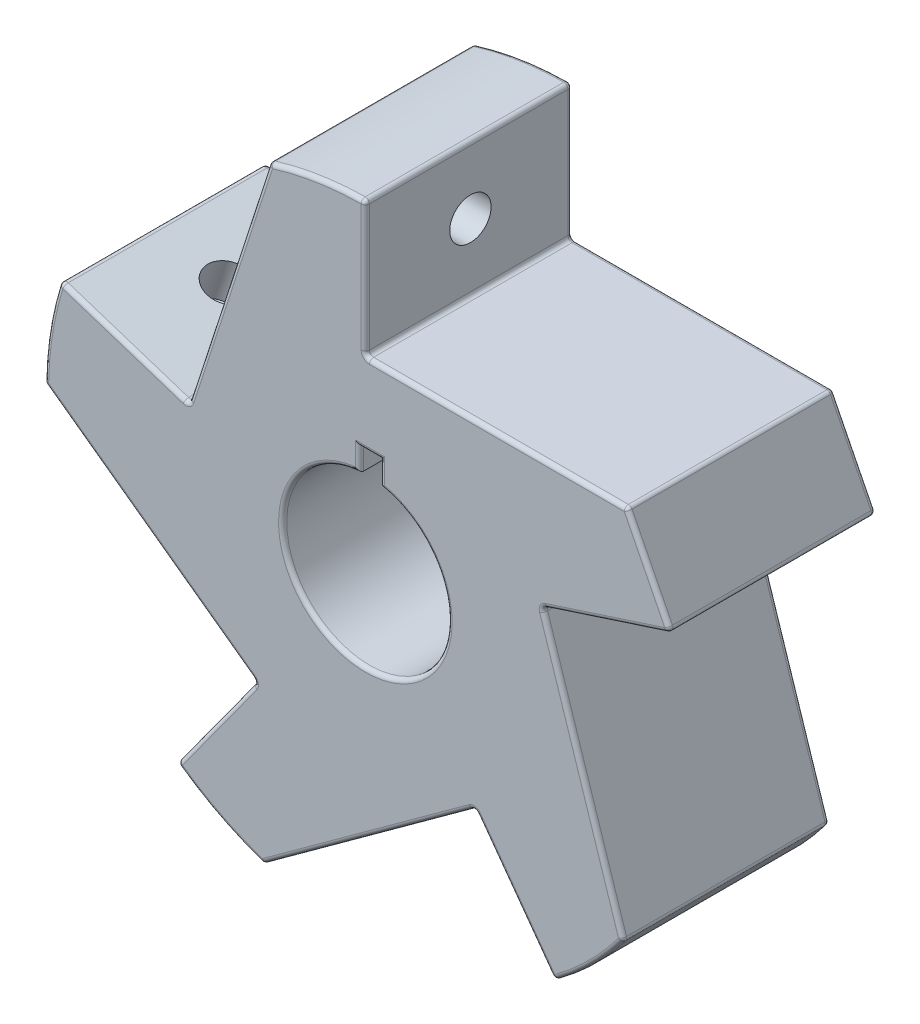
from build123d import *

# Parameters (mm, degrees)
SKETCH1_R           = 20
BOSS_EXTRUDE2_DEPTH = 50
SKETCH2_W           = 5
SKETCH2_H           = 11
CUT_EXTRUDE3_DEPTH  = 60
FILLET1_R           = 1
SKETCH3_R           = 5.003643642
CUT_EXTRUDE4_DEPTH  = 10
SKETCH4_R           = 5
CUT_EXTRUDE5_DEPTH  = 10
SKETCH5_R           = 5
CUT_EXTRUDE6_DEPTH  = 10
SKETCH6_R           = 5
CUT_EXTRUDE7_DEPTH  = 10
SKETCH7_R           = 5
CUT_EXTRUDE8_DEPTH  = 10


with BuildPart() as part:
    # Sketch1 → Boss-Extrude2 (new body)
    with BuildSketch(Plane.XY):
        with BuildLine():
            Line((-23.253592475, 74.055860248), (-42.797543233, 13.905764747))
            Line((-42.797543233, 13.905764747), (-73.821837525, 23.986169024))
            ThreePointArc((-73.821837525, 23.986169024), (-76.604138186, 12.522220762), (-77.617063713, 0.769038699))
            Line((-77.617063713, 0.769038699), (-26.450336353, -36.405764747))
            Line((-26.450336353, -36.405764747), (-45.624404702, -62.796605765))
            ThreePointArc((-45.624404702, -62.796605765), (-35.581320193, -68.985285774), (-24.716391007, -73.580568193))
            Line((-24.716391007, -73.580568193), (26.450336353, -36.405764747))
            Line((26.450336353, -36.405764747), (45.624404702, -62.796605765))
            ThreePointArc((45.624404702, -62.796605765), (54.613672942, -55.157472094), (62.341493992, -46.244330754))
            Line((62.341493992, -46.244330754), (42.797543233, 13.905764747))
            Line((42.797543233, 13.905764747), (73.821837525, 23.986169024))
            Line((73.821837525, 23.986169024), (63.245553203, 45))
            Line((63.245553203, 45), (0, 45))
            Line((0, 45), (0, 77.620873481))
            ThreePointArc((0, 77.620873481), (-11.762640885, 76.72444382), (-23.253592475, 74.055860248))
        make_face()
        Circle(SKETCH1_R, mode=Mode.SUBTRACT)
    extrude(amount=BOSS_EXTRUDE2_DEPTH)

    # Sketch2 → Cut-Extrude3 (cut)
    with BuildSketch(Plane.XY):
        with Locations((1.091953982, 19.974403848)):
            Rectangle(SKETCH2_W, SKETCH2_H)
    extrude(amount=CUT_EXTRUDE3_DEPTH, mode=Mode.SUBTRACT)

    # Fillet1
    fillet1_edges = [part.edges().sort_by_distance(p)[0] for p in [
        (-11.762640885, 76.72444382, 50),
        (-33.025567854, 43.980812497, 50),
        (31.622776602, 45, 0),
        (68.533695364, 34.493084512, 0),
        (58.309690379, 18.945966885, 0),
        (52.569518613, -16.169283004, 0),
        (54.613672942, -55.157472094, 0),
        (36.037370528, -49.601185256, 0),
        (-58.309690379, 18.945966885, 50),
        (0.866972673, -54.99316647, 0),
        (-35.581320193, -68.985285774, 0),
        (-36.037370528, -49.601185256, 0),
        (-52.033700033, -17.818363024, 0),
        (-76.604138186, 12.522220762, 0),
        (-58.309690379, 18.945966885, 0),
        (-33.025567854, 43.980812497, 0),
        (-11.762640885, 76.72444382, 0),
        (0, 61.310436741, 0),
        (-76.604138186, 12.522220762, 50),
        (0, 45, 25),
        (63.245553203, 45, 25),
        (73.821837525, 23.986169024, 25),
        (42.797543233, 13.905764747, 25),
        (62.341493992, -46.244330754, 25),
        (-52.033700033, -17.818363024, 50),
        (45.624404702, -62.796605765, 25),
        (26.450336353, -36.405764747, 25),
        (-24.716391007, -73.580568193, 25),
        (-45.624404702, -62.796605765, 25),
        (-26.450336353, -36.405764747, 25),
        (-77.617063713, 0.769038699, 25),
        (-73.821837525, 23.986169024, 25),
        (-42.797543233, 13.905764747, 25),
        (-23.253592475, 74.055860248, 25),
        (0, 77.620873481, 25),
        (-36.037370528, -49.601185256, 50),
        (-35.581320193, -68.985285774, 50),
        (0.866972673, -54.99316647, 50),
        (-1.100612697, -19.96969333, 0),
        (36.037370528, -49.601185256, 50),
        (-1.100612697, -19.96969333, 50),
        (54.613672942, -55.157472094, 50),
        (-1.408046018, 22.712388719, 50),
        (3.591953982, 22.574603341, 50),
        (1.091953982, 25.474403848, 50),
        (0, 61.310436741, 50),
        (52.569518613, -16.169283004, 50),
        (58.309690379, 18.945966885, 50),
        (68.533695364, 34.493084512, 50),
        (31.622776602, 45, 50),
    ]]
    fillet(fillet1_edges, radius=FILLET1_R)

    # Sketch3 → Cut-Extrude4 (cut)
    with BuildSketch(Plane(origin=(0, 0, 0), x_dir=(0, 0, -1), z_dir=(1, 0, 0))):
        with Locations((-24.586318369, 61.307173783)):
            Circle(SKETCH3_R)
    extrude(amount=-CUT_EXTRUDE4_DEPTH, mode=Mode.SUBTRACT)

    # Sketch4 → Cut-Extrude5 (cut)
    with BuildSketch(Plane(origin=(0, 0, 0), x_dir=(0.951056516, 0.309016994, 0), z_dir=(0.309016994, -0.951056516, 0))):
        with Locations((60.51506778, 25)):
            Circle(SKETCH4_R)
    extrude(amount=-CUT_EXTRUDE5_DEPTH, mode=Mode.SUBTRACT)

    # Sketch5 → Cut-Extrude6 (cut)
    with BuildSketch(Plane(origin=(0, 0, 0), x_dir=(0, 0, 1), z_dir=(-0.809016994, -0.587785252, 0))):
        with Locations((25, -60.594301807)):
            Circle(SKETCH5_R)
    extrude(amount=-CUT_EXTRUDE6_DEPTH, mode=Mode.SUBTRACT)

    # Sketch6 → Cut-Extrude7 (cut)
    with BuildSketch(Plane(origin=(0, 0, 0), x_dir=(0, 0, 1), z_dir=(-0.809016994, 0.587785252, 0))):
        with Locations((25, -61.307173783)):
            Circle(SKETCH6_R)
    extrude(amount=-CUT_EXTRUDE7_DEPTH, mode=Mode.SUBTRACT)

    # Sketch7 → Cut-Extrude8 (cut)
    with BuildSketch(Plane(origin=(0, 0, 0), x_dir=(0.951056516, -0.309016994, 0), z_dir=(0.309016994, 0.951056516, 0))):
        with Locations((-61.307173783, -25)):
            Circle(SKETCH7_R)
    extrude(amount=-CUT_EXTRUDE8_DEPTH, mode=Mode.SUBTRACT)


solid = part.part
